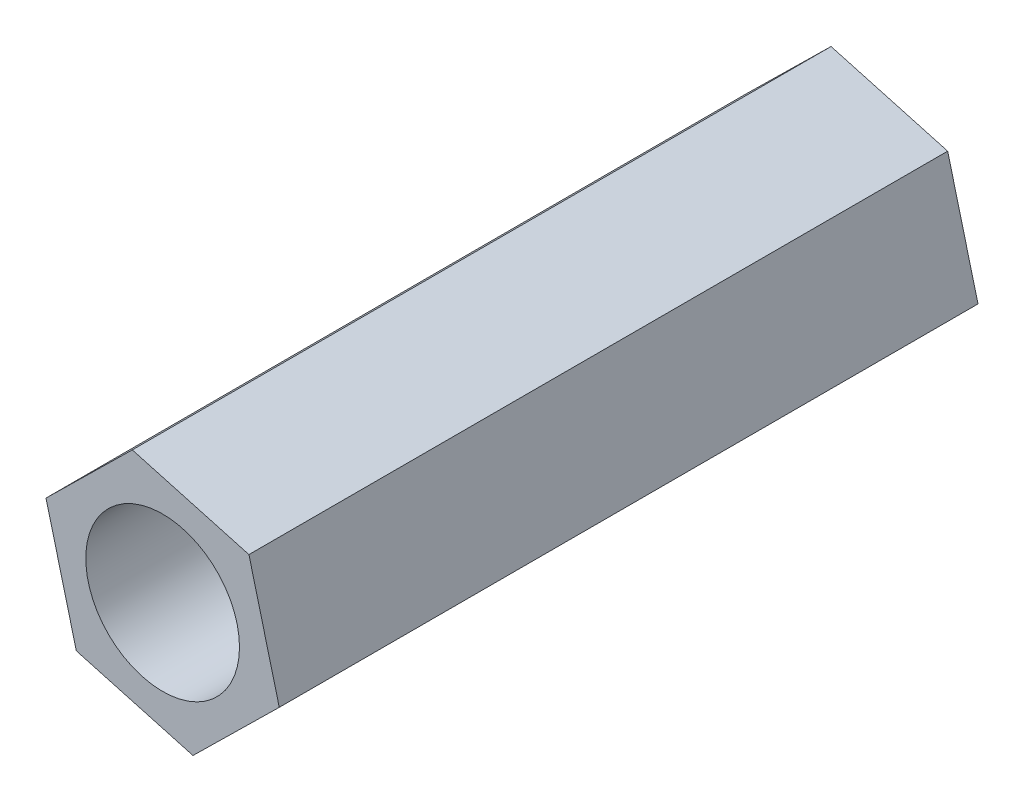
from build123d import *

# Parameters (mm, degrees)
SKETCH_1_R      = 1.65
EXTRUDE_1_DEPTH = 15


with BuildPart() as part:
    # 草图1 → 凸台-拉伸1 (new body)
    with BuildSketch(Plane.XY):
        Polygon((1.852685253, 1.821416304), (-0.651050163, 2.515180647), (-2.503735417, 0.693764343), (-1.852685253, -1.821416304), (0.651050163, -2.515180647), (2.503735417, -0.693764343), align=None)
        Circle(SKETCH_1_R, mode=Mode.SUBTRACT)
    extrude(amount=EXTRUDE_1_DEPTH)


solid = part.part
